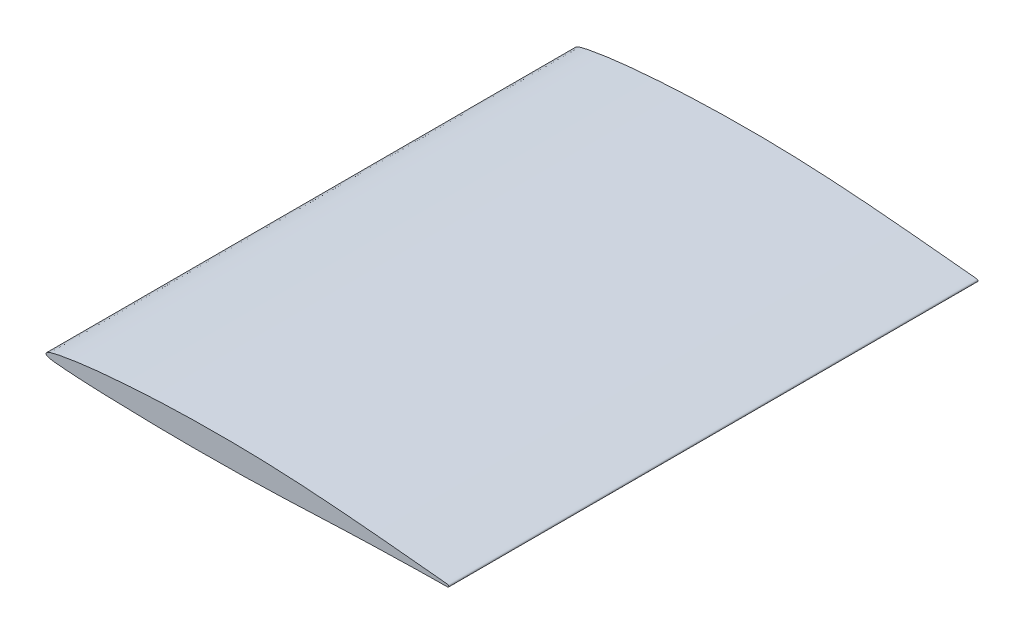
from build123d import *

# Parameters (mm, degrees)
AUFSATZ_LINEAR_AUSTRAGEN1_DEPTH = 197


with BuildPart() as part:
    # Skizze1 → Aufsatz-Linear austragen1 (new body)
    with BuildSketch(Plane.XY):
        with BuildLine():
            add(Edge.make_bspline(
                [(150, 0), (149.998190148, 0.042053915), (149.979473881, 0.133396788), (149.888190168, 0.251098183), (149.763898175, 0.354236402), (149.604124375, 0.419294252), (149.428635817, 0.446344471), (149.245665099, 0.455610092), (149.057952583, 0.467945111), (148.866166383, 0.481311615), (148.669612554, 0.500129065), (148.466983195, 0.52015702), (148.257644315, 0.541113941), (148.041386731, 0.563533181), (147.817640491, 0.585069777), (147.586002444, 0.608357752), (147.346639736, 0.632064929), (147.099394392, 0.65761207), (146.843918143, 0.681849297), (146.580068611, 0.709682859), (146.307310274, 0.736102275), (146.025670935, 0.764376002), (145.734665895, 0.793325616), (145.433994189, 0.823275132), (145.123667218, 0.8543388), (144.80333708, 0.886371093), (144.472674046, 0.919406323), (144.13127101, 0.953049474), (143.779406439, 0.989725224), (143.4160063, 1.02539858), (143.040950994, 1.062174888), (142.654018069, 1.101513686), (142.255006351, 1.141396779), (141.844015841, 1.182492294), (141.420293821, 1.224271534), (140.983686755, 1.268533451), (140.533358169, 1.313582903), (140.069292935, 1.359261736), (139.591357086, 1.407570865), (139.099366277, 1.456664304), (138.59289358, 1.505938215), (138.071781019, 1.560141475), (137.534955932, 1.612223716), (136.982647055, 1.667470739), (136.415032034, 1.724653925), (135.830986725, 1.782533376), (135.230641991, 1.842420538), (134.613370843, 1.904707836), (133.979380267, 1.967808538), (133.327910008, 2.031092345), (132.659446754, 2.099146504), (131.97264473, 2.16544427), (131.267985989, 2.23452314), (130.54504636, 2.305808053), (129.803653945, 2.377536103), (129.04365527, 2.451549585), (128.264384975, 2.527865361), (127.466034627, 2.604695135), (126.648000074, 2.682667342), (125.810979132, 2.762448437), (124.954054481, 2.844904667), (124.077706795, 2.927760512), (123.181316383, 3.011485481), (122.26505545, 3.097927496), (121.328689316, 3.184577099), (120.372434395, 3.273109725), (119.396307005, 3.360376466), (118.400043637, 3.450816404), (117.383749063, 3.541930869), (116.347353371, 3.632561798), (115.291421446, 3.725021145), (114.21567826, 3.816469507), (113.120748092, 3.909967162), (112.006343883, 4.002459487), (110.873116293, 4.097086512), (109.720719086, 4.189657334), (108.550059576, 4.282755984), (107.361376069, 4.375547951), (106.154773379, 4.4690708), (104.930692145, 4.560339167), (103.689803156, 4.653206904), (102.43235531, 4.742310602), (101.159121509, 4.833079784), (99.870056599, 4.920508745), (98.56643421, 5.007866463), (97.248424267, 5.092771687), (95.916747697, 5.175651341), (94.572116642, 5.256984088), (93.21539887, 5.33449456), (91.847103973, 5.410912251), (90.46808801, 5.483709676), (89.078749726, 5.553683422), (87.680772035, 5.620943056), (86.274068319, 5.683568256), (84.860090219, 5.743867901), (83.439410772, 5.799706496), (82.013077156, 5.851882439), (80.582043483, 5.899331043), (79.146749208, 5.945119094), (77.708714807, 5.984497788), (76.268728665, 6.020987324), (74.827705324, 6.05161499), (73.386700482, 6.07858893), (71.946370468, 6.101944922), (70.508020925, 6.119572192), (69.072350228, 6.133670336), (67.640344399, 6.143648172), (66.213005555, 6.149666682), (64.79133355, 6.151636939), (63.37599352, 6.149784789), (61.967993713, 6.143282218), (60.56797599, 6.135221518), (59.177325, 6.120059406), (57.796305489, 6.104864871), (56.425963668, 6.084872749), (55.066983645, 6.060220531), (53.720287128, 6.034913452), (52.386278366, 6.004919074), (51.065972306, 5.970369398), (49.759948931, 5.934782016), (48.468943271, 5.895787056), (47.193293893, 5.853496428), (45.933267107, 5.809834036), (44.68959146, 5.762903685), (43.462949629, 5.712545204), (42.253904109, 5.661142696), (41.062971498, 5.605278066), (39.889888136, 5.550262719), (38.735298883, 5.490331201), (37.599538309, 5.431352195), (36.483287078, 5.367466477), (35.386230667, 5.304055547), (34.308601829, 5.237703152), (33.250592019, 5.170827679), (32.212589817, 5.102819808), (31.194584349, 5.033860096), (30.196582874, 4.963843168), (29.218898864, 4.893032147), (28.261289286, 4.820579381), (27.323891979, 4.749053356), (26.406227346, 4.675970373), (25.508937445, 4.601752523), (24.631539735, 4.528144439), (23.774264992, 4.452768513), (22.936589737, 4.377853171), (22.118196333, 4.303134338), (21.319576927, 4.226927025), (20.540252, 4.150829843), (19.780162108, 4.075341918), (19.039311256, 3.997545875), (18.316819176, 3.92235263), (17.612914243, 3.844775445), (16.927125326, 3.768481169), (16.259633268, 3.68961391), (15.60953495, 3.613100264), (14.976870532, 3.536050162), (14.36151638, 3.459179657), (13.763296231, 3.381623946), (13.181415857, 3.306547684), (12.615947958, 3.228706199), (12.066256245, 3.152891986), (11.532152153, 3.078268192), (11.013617715, 3.00266954), (10.509815377, 2.929239974), (10.020914101, 2.854893457), (9.546575255, 2.781923235), (9.086251829, 2.709848836), (8.639582827, 2.638860019), (8.206133191, 2.569217679), (7.786345145, 2.498593854), (7.378916017, 2.430835207), (6.983815688, 2.364070801), (6.601218864, 2.296977585), (6.230291395, 2.230571279), (5.87108189, 2.16636611), (5.523288378, 2.100570767), (5.186446565, 2.037142014), (4.86015852, 1.972877945), (4.544413738, 1.909224047), (4.238947949, 1.844580939), (3.94307057, 1.782213138), (3.657244852, 1.718732218), (3.380323594, 1.65716298), (3.113085243, 1.594032451), (2.854921704, 1.531318808), (2.606112261, 1.467405867), (2.366730545, 1.400961456), (2.135341165, 1.335576236), (1.913273723, 1.267609625), (1.70016037, 1.197174851), (1.494825199, 1.126676978), (1.297819452, 1.053026111), (1.107496383, 0.979889246), (0.925305096, 0.902338922), (0.748624026, 0.822584584), (0.578993139, 0.735619267), (0.419837139, 0.638878343), (0.276193744, 0.532803048), (0.156779193, 0.413844439), (0.065366254, 0.284227223), (0.007915834, 0.145103723), (-0.008010812, -0.000360682), (0.02494008, -0.14295072), (0.096050619, -0.275753759), (0.203706745, -0.392062197), (0.33939155, -0.489717947), (0.496288337, -0.571301105), (0.669329264, -0.637995784), (0.849849305, -0.698339519), (1.036299935, -0.752218876), (1.227764055, -0.802288446), (1.425970693, -0.848924751), (1.631183369, -0.894307824), (1.844255886, -0.936220195), (2.065413881, -0.974824501), (2.294651219, -1.01229345), (2.532478337, -1.045726441), (2.77879721, -1.07797212), (3.033572515, -1.107500269), (3.297214383, -1.13678406), (3.569962766, -1.164375433), (3.851958008, -1.192425435), (4.143279157, -1.220577212), (4.444030621, -1.247999237), (4.754541534, -1.278052459), (5.075094873, -1.304602038), (5.405873532, -1.336104151), (5.747363752, -1.3639833), (6.099618521, -1.39456824), (6.462958174, -1.424518153), (6.838008777, -1.454224681), (7.2249633, -1.485458117), (7.623915606, -1.516792004), (8.035021376, -1.546042401), (8.458615413, -1.577710701), (8.895352654, -1.608059799), (9.345583526, -1.640869203), (9.809645652, -1.671325296), (10.287630381, -1.702567118), (10.779683111, -1.733071459), (11.28626062, -1.765847745), (11.807976182, -1.796416352), (12.345013122, -1.82710147), (12.897268697, -1.859813538), (13.465316375, -1.890321019), (14.049641404, -1.921480514), (14.650313676, -1.952386863), (15.267644808, -1.983441872), (15.901982246, -2.014365003), (16.55362021, -2.045672617), (17.222986017, -2.075320242), (17.909982467, -2.105404674), (18.6149838, -2.135387517), (19.338320048, -2.165320764), (20.080294485, -2.195655842), (20.840989896, -2.224274097), (21.62065529, -2.25330282), (22.419297192, -2.282695252), (23.237680543, -2.309932329), (24.075301167, -2.339613318), (24.932305274, -2.367560979), (25.809012002, -2.393946044), (26.705305743, -2.422566911), (27.621641298, -2.44956362), (28.557679831, -2.47486036), (29.513638891, -2.502678458), (30.489664679, -2.528077047), (31.485643205, -2.554591041), (32.501664793, -2.579078221), (33.537312661, -2.60454738), (34.592664871, -2.628082519), (35.667316108, -2.652455932), (36.761319646, -2.675342227), (37.8743205, -2.697332843), (39.005986708, -2.718412759), (40.156333471, -2.737989362), (41.324979213, -2.758605389), (42.511983981, -2.776476335), (43.716659389, -2.792243623), (44.938326948, -2.807194682), (46.176653956, -2.821557162), (47.431329436, -2.833099582), (48.7016576, -2.844477019), (49.987327121, -2.853335391), (51.287328311, -2.860468208), (52.601665421, -2.864972161), (53.929329971, -2.869788893), (55.269666798, -2.869946517), (56.622000589, -2.870433107), (57.985335583, -2.868300342), (59.359670052, -2.864296338), (60.743672192, -2.858401133), (62.136668496, -2.849971014), (63.537344648, -2.841572087), (64.945348985, -2.829585851), (66.35966892, -2.813885244), (67.779687521, -2.798701823), (69.204011274, -2.779132203), (70.632358869, -2.758627707), (72.063348392, -2.734188213), (73.496362704, -2.708547891), (74.929700449, -2.67957336), (76.363019825, -2.647197928), (77.795374251, -2.613654525), (79.226026541, -2.576320399), (80.6540265, -2.537290971), (82.078053678, -2.496789935), (83.49734528, -2.452042498), (84.911038809, -2.40752927), (86.318370864, -2.360430172), (87.718376627, -2.311540458), (89.110022586, -2.260273062), (90.49302612, -2.208353227), (91.866360472, -2.155361618), (93.229032335, -2.101470468), (94.580007613, -2.046185238), (95.919010734, -1.99126052), (97.245345088, -1.936282227), (98.558679962, -1.881315428), (99.857659098, -1.82615428), (101.142320571, -1.772028474), (102.411689397, -1.719542048), (103.66529755, -1.665809417), (104.902666568, -1.615330572), (106.123301092, -1.564869753), (107.326997078, -1.517257863), (108.512995723, -1.470226209), (109.680973222, -1.423978948), (110.830973644, -1.379965708), (111.962329156, -1.33821754), (113.07499947, -1.297326175), (114.168281191, -1.256529153), (115.242689351, -1.220648792), (116.297305726, -1.182871232), (117.332642568, -1.147933742), (118.347999113, -1.115307956), (119.343640401, -1.082832683), (120.319329143, -1.053191852), (121.275329526, -1.024211987), (122.21164066, -0.995772102), (123.12801107, -0.970385962), (124.024679245, -0.944430023), (124.901303099, -0.917619329), (125.758699229, -0.894791569), (126.596319779, -0.868872227), (127.414348001, -0.84549477), (128.212987364, -0.820908372), (128.992681814, -0.798509113), (129.753639858, -0.774753728), (130.49599508, -0.754149858), (131.219661769, -0.734161839), (131.925309665, -0.714747837), (132.612996572, -0.698190981), (133.28297999, -0.681792558), (133.935317265, -0.667870625), (134.570317547, -0.655764196), (135.188661001, -0.64595895), (135.790335458, -0.637142847), (136.375670123, -0.628221954), (136.944657611, -0.618740187), (137.498013425, -0.611525681), (138.035659083, -0.601864993), (138.558325614, -0.593799749), (139.06601299, -0.587533726), (139.559324159, -0.578734411), (140.038336265, -0.572195706), (140.503334721, -0.565090416), (140.954667991, -0.558084208), (141.392669664, -0.551187544), (141.817658565, -0.543811187), (142.230002537, -0.538168492), (142.630000632, -0.532041543), (143.018003255, -0.526211366), (143.393990455, -0.519695556), (143.758679708, -0.515516716), (144.111990359, -0.508718572), (144.454669284, -0.504172207), (144.78600067, -0.499043111), (145.107336019, -0.494175959), (145.418657005, -0.488678777), (145.720679603, -0.48551872), (146.012656855, -0.479702391), (146.29533559, -0.476150355), (146.569000589, -0.472040702), (146.834001319, -0.468085936), (147.090667011, -0.464020281), (147.339002844, -0.460182296), (147.579323836, -0.455694957), (147.811677612, -0.453383971), (148.036334891, -0.449084188), (148.253657139, -0.444735919), (148.463670658, -0.442310193), (148.667318373, -0.438337044), (148.866012962, -0.438495338), (149.060690482, -0.441600891), (149.251313708, -0.446838231), (149.432746384, -0.452472324), (149.606904242, -0.433016803), (149.764898335, -0.371788991), (149.901076159, -0.278948468), (149.988367122, -0.146568992), (150.0020505, -0.047645616), (150, 0)],
                knots=[0, 0, 0, 0, 0.000413837, 0.000903584, 0.001445149, 0.002006154, 0.002591512, 0.003202433, 0.003826351, 0.004460634, 0.005112512, 0.005788097, 0.006483785, 0.007202871, 0.007948322, 0.00871717, 0.009516008, 0.010338244, 0.011186846, 0.012065767, 0.012974346, 0.013909619, 0.014878176, 0.015880018, 0.01691185, 0.017976967, 0.019078664, 0.020213646, 0.02138554, 0.022593683, 0.023841703, 0.025129928, 0.026458028, 0.027826004, 0.029233857, 0.030688506, 0.032186326, 0.033730613, 0.035321697, 0.036959248, 0.038643267, 0.040377709, 0.042164879, 0.044002139, 0.045892787, 0.047833197, 0.049833587, 0.051887363, 0.053997494, 0.056163981, 0.058390773, 0.060673596, 0.063019692, 0.065425765, 0.067891493, 0.070420494, 0.073012769, 0.075671293, 0.078389477, 0.081177526, 0.084025552, 0.086943129, 0.089923667, 0.092970773, 0.096087438, 0.099267068, 0.102512664, 0.105824826, 0.109206557, 0.11265097, 0.116161659, 0.119738342, 0.123378006, 0.127080376, 0.130849032, 0.134676834, 0.138567364, 0.142517324, 0.146523419, 0.150592009, 0.154713443, 0.158887247, 0.163117214, 0.167396281, 0.171724692, 0.176098937, 0.180519038, 0.184981709, 0.189483472, 0.194021234, 0.198598144, 0.203204309, 0.207843066, 0.212504369, 0.217195019, 0.221904982, 0.226630991, 0.231376397, 0.236131411, 0.240899177, 0.245669905, 0.250443559, 0.255220257, 0.259990103, 0.264756402, 0.269512617, 0.274255475, 0.278985011, 0.283694637, 0.28838108, 0.293047689, 0.297684544, 0.302291728, 0.306865866, 0.311407061, 0.315908731, 0.320370786, 0.324790072, 0.329166634, 0.333493711, 0.337771415, 0.341999778, 0.346175405, 0.350298436, 0.354365596, 0.358373471, 0.362322231, 0.366211597, 0.370041911, 0.373809554, 0.377511598, 0.381151007, 0.384727997, 0.388239081, 0.391684275, 0.395063597, 0.398377064, 0.401624696, 0.404803209, 0.407918976, 0.410965662, 0.413949892, 0.416864812, 0.419714019, 0.422500544, 0.4252211, 0.427879308, 0.430471583, 0.433001235, 0.435468619, 0.437873074, 0.440218606, 0.442504885, 0.444729023, 0.446896857, 0.449008788, 0.451061553, 0.453058462, 0.455002394, 0.456890955, 0.458729847, 0.460515798, 0.462249288, 0.463936418, 0.465574411, 0.467162793, 0.468704849, 0.470203859, 0.471656561, 0.473066776, 0.474433433, 0.475760347, 0.477048095, 0.478292867, 0.479504455, 0.480673698, 0.481809781, 0.482910094, 0.483977925, 0.485010076, 0.486012378, 0.486982311, 0.487919194, 0.488830997, 0.489710592, 0.49055887, 0.491383252, 0.492178932, 0.492947908, 0.493690477, 0.494408999, 0.495104812, 0.495780129, 0.496434636, 0.497071921, 0.497705919, 0.498327335, 0.498920843, 0.499475883, 0.499994944, 0.500486958, 0.500956242, 0.501423969, 0.501918818, 0.502437022, 0.50298418, 0.50357235, 0.504189213, 0.504824948, 0.505463231, 0.506117133, 0.506791125, 0.507486245, 0.508205278, 0.508948533, 0.50971681, 0.510513062, 0.511334671, 0.512185048, 0.513061376, 0.513970287, 0.514908855, 0.51587709, 0.516878297, 0.517909491, 0.51897667, 0.520074127, 0.521210886, 0.522380926, 0.52358727, 0.524833227, 0.526119066, 0.527444524, 0.528809366, 0.530214086, 0.531665054, 0.533159205, 0.534699385, 0.536285833, 0.537918554, 0.539597759, 0.541329653, 0.543111142, 0.54494242, 0.546826418, 0.548763332, 0.550756473, 0.552802536, 0.554904834, 0.557066678, 0.559284613, 0.561562106, 0.563899158, 0.566295773, 0.568755263, 0.571277502, 0.573859314, 0.576507321, 0.5792181, 0.581995192, 0.584835066, 0.58773773, 0.590710014, 0.593745097, 0.596846297, 0.600013804, 0.603247434, 0.60654728, 0.609913261, 0.613345461, 0.616840494, 0.620401749, 0.624025846, 0.627712789, 0.631462585, 0.635271927, 0.639144187, 0.643075948, 0.647067224, 0.651114757, 0.655215239, 0.659371952, 0.663581624, 0.667837611, 0.672146547, 0.676498508, 0.680896825, 0.685338178, 0.689815962, 0.694333495, 0.698884162, 0.703471284, 0.708084935, 0.712725102, 0.717388526, 0.722075227, 0.726778524, 0.731498501, 0.736228507, 0.740971915, 0.74571875, 0.750469086, 0.755216323, 0.759963713, 0.764704727, 0.769435984, 0.774157495, 0.77885944, 0.783544938, 0.788210789, 0.792850387, 0.797463744, 0.802047435, 0.806601467, 0.811119225, 0.815597403, 0.820035871, 0.824434629, 0.82878706, 0.833096474, 0.837352803, 0.841562667, 0.845719586, 0.849819974, 0.853867279, 0.857858059, 0.861789139, 0.86566052, 0.869472073, 0.873223803, 0.876909217, 0.880534934, 0.8840941, 0.887590377, 0.891020226, 0.894386963, 0.897684077, 0.900918087, 0.904085788, 0.907187179, 0.910225476, 0.913194251, 0.916100125, 0.918939597, 0.921716263, 0.924426621, 0.927070768, 0.929655228, 0.932176789, 0.934635255, 0.937034036, 0.939369823, 0.941649154, 0.943868807, 0.94602871, 0.948132187, 0.950179252, 0.952173282, 0.954111014, 0.955995761, 0.957827472, 0.959609561, 0.961338613, 0.963021254, 0.96465427, 0.966240874, 0.967781114, 0.969274993, 0.970725821, 0.9721336, 0.973498276, 0.974823213, 0.976108412, 0.977353871, 0.978559542, 0.979732148, 0.980864963, 0.981964662, 0.983024622, 0.984058089, 0.985058392, 0.986025629, 0.986959699, 0.987867276, 0.988745048, 0.989593016, 0.990417803, 0.991212786, 0.991981228, 0.992726539, 0.993445358, 0.994140943, 0.994813347, 0.995469117, 0.996115028, 0.996747831, 0.997363866, 0.99791846, 0.998475118, 0.999032248, 0.999531137, 1, 1, 1, 1], degree=3))
        make_face()
    extrude(amount=AUFSATZ_LINEAR_AUSTRAGEN1_DEPTH)


solid = part.part
